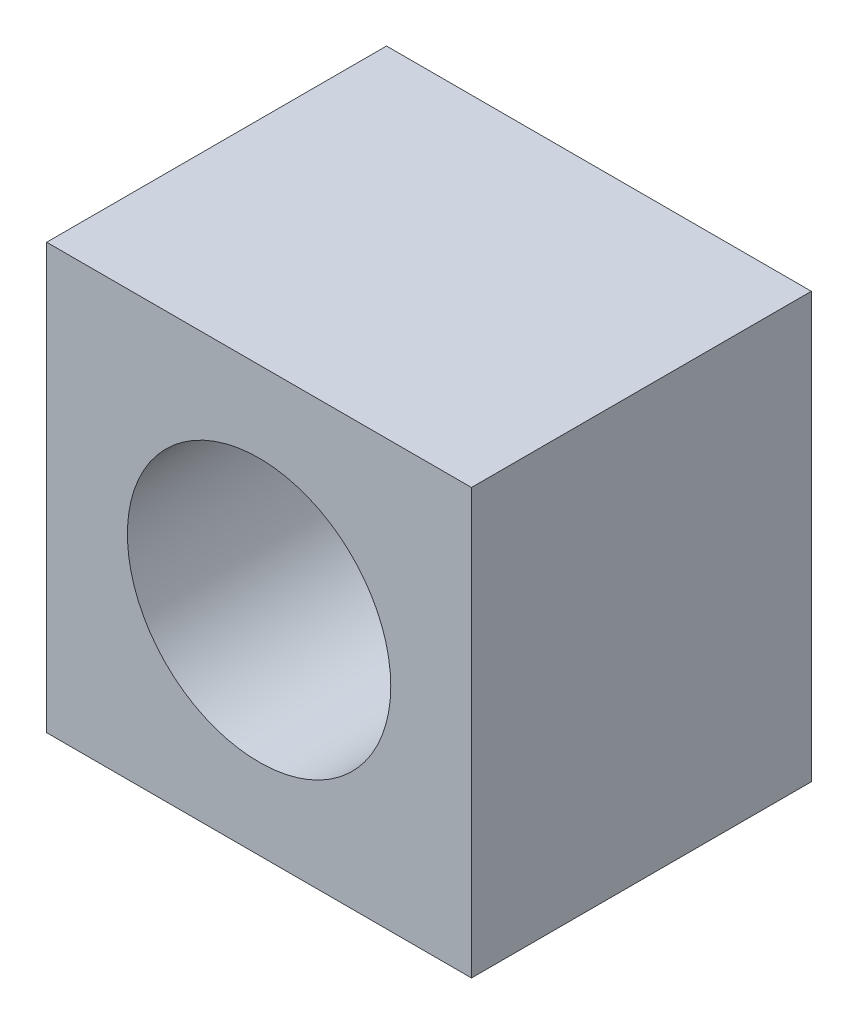
from build123d import *

# Parameters (mm, degrees)
SKETCH1_W          = 10
SKETCH1_H          = 10
SKETCH1_R          = 1.25
MAIN_DEPTH         = 8
SKETCH2_R          = 3.1
CUT_EXTRUDE1_DEPTH = 5


with BuildPart() as part:
    # Sketch1 → Main (new body)
    with BuildSketch(Plane.XY):
        Rectangle(SKETCH1_W, SKETCH1_H)
        Circle(SKETCH1_R, mode=Mode.SUBTRACT)
    extrude(amount=MAIN_DEPTH)

    # Sketch2 → Cut-Extrude1 (cut)
    with BuildSketch(Plane.XY.offset(8)):
        Circle(SKETCH2_R)
    extrude(amount=-CUT_EXTRUDE1_DEPTH, mode=Mode.SUBTRACT)


solid = part.part
